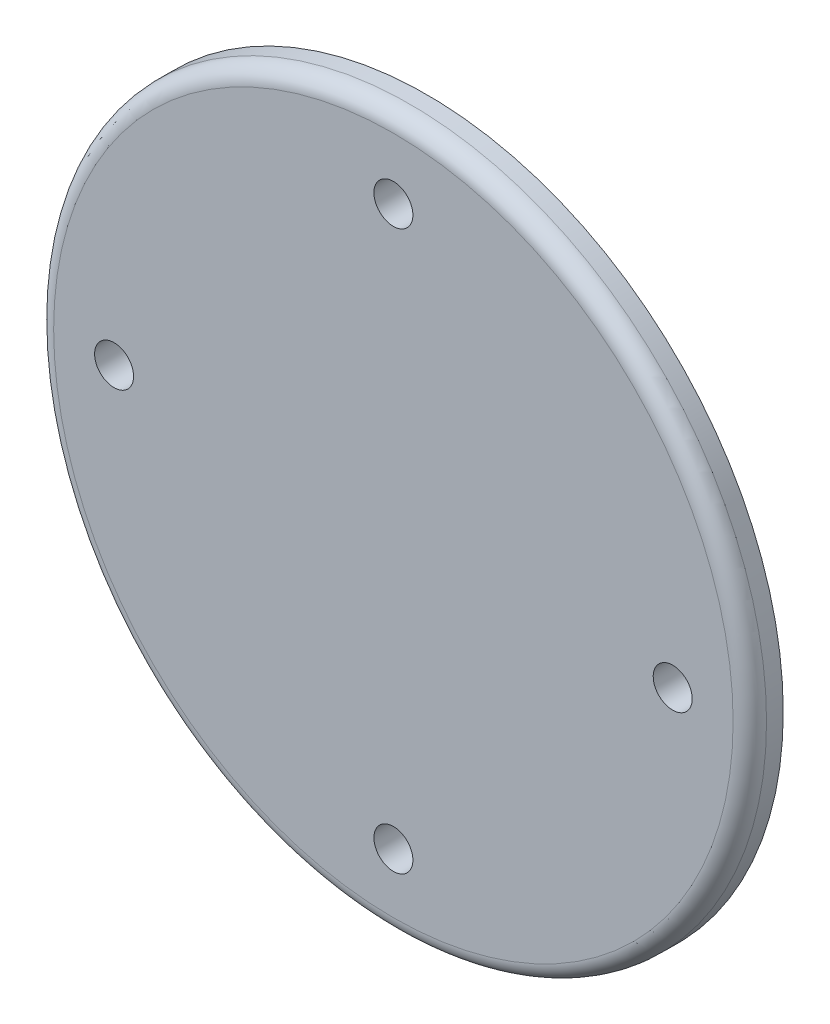
from build123d import *

# Parameters (mm, degrees)
SKICA2_R                 = 3.5
ODEBRAT_VYSUNUT_M1_DEPTH = 6
KRUHOV_POLE1_COUNT       = 4
ZAOBLIT1_R               = 3
ZAOBLIT2_R               = 1
ZAOBLIT3_R               = 5


with BuildPart() as part:
    # Skica1 → Rotovat1 (revolve)
    with BuildSketch(Plane(origin=(0, 0, 0), x_dir=(0, 0, -1), z_dir=(1, 0, 0))):
        Polygon((0, 64), (0, 0), (6, 0), (6, 29), (16, 29), (16, 34), (6, 34), (6, 64), align=None)
    revolve(axis=Axis((0, 0, 30.782343988), (0, 0, -1)))

    # Skica2 → Odebrat vysunutím1 (cut)
    with BuildSketch(Plane.XY):
        with Locations((0, 50)):
            Circle(SKICA2_R)
    odebrat_vysunut_m1 = extrude(amount=-ODEBRAT_VYSUNUT_M1_DEPTH, mode=Mode.SUBTRACT)

    # Kruhové pole1: Odebrat vysunutím1 ×4 about axis
    kruhov_pole1_axis = Axis((0, -0.149984695, 0), (0, 0, 1))
    for i in range(1, KRUHOV_POLE1_COUNT):
        add(odebrat_vysunut_m1.rotate(kruhov_pole1_axis, i * 360 / KRUHOV_POLE1_COUNT), mode=Mode.SUBTRACT)

    # Zaoblit1
    zaoblit1_edges = [part.edges().sort_by_distance(p)[0] for p in [
        (0, -64, 0),
    ]]
    fillet(zaoblit1_edges, radius=ZAOBLIT1_R)

    # Zaoblit2
    zaoblit2_edges = [part.edges().sort_by_distance(p)[0] for p in [
        (0, -34, -6),
    ]]
    fillet(zaoblit2_edges, radius=ZAOBLIT2_R)

    # Zaoblit3
    zaoblit3_edges = [part.edges().sort_by_distance(p)[0] for p in [
        (0, -29, -6),
    ]]
    fillet(zaoblit3_edges, radius=ZAOBLIT3_R)


solid = part.part
